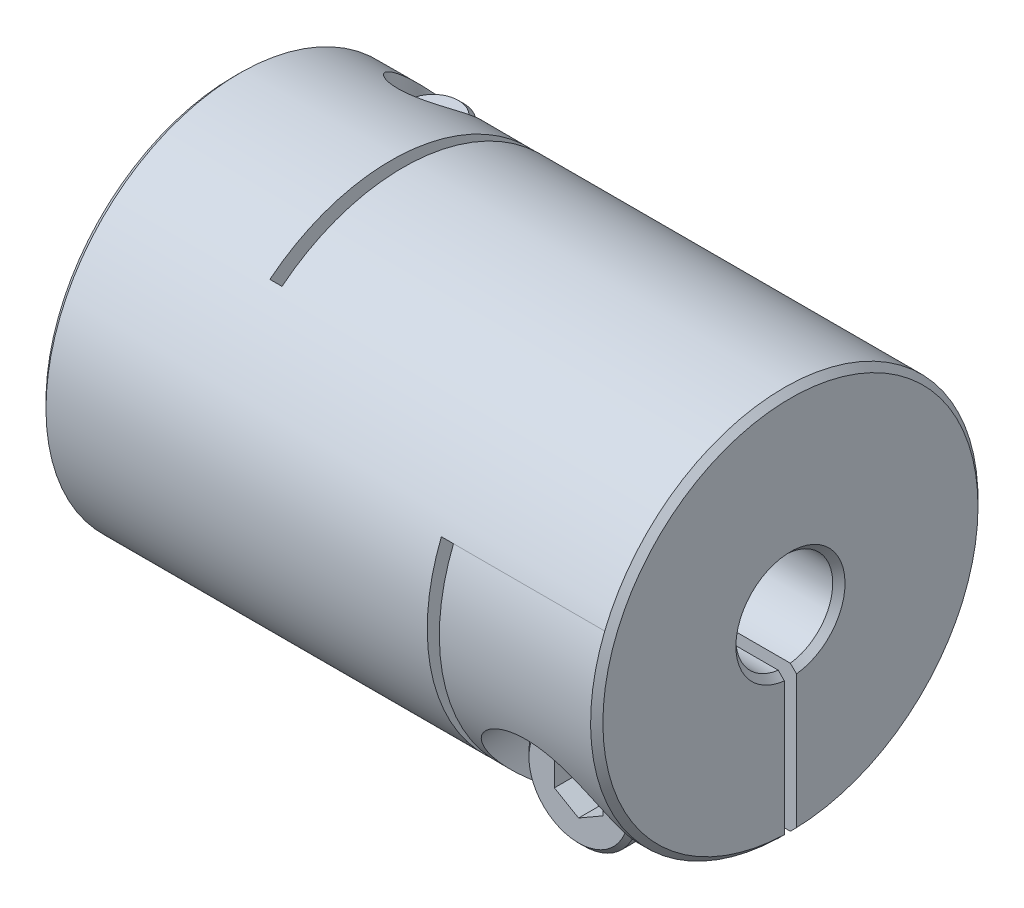
from build123d import *

# Parameters (mm, degrees)
SKETCH1_R                        = 8
BOSS_EXTRUDE1_DEPTH              = 11.5
SKETCH2_R                        = 2
CUT_EXTRUDE1_DEPTH               = 24
CHAMFER1_SIZE                    = 0.254
SKETCH4_W                        = 0.5
SKETCH4_H                        = 13
CUT_EXTRUDE2_DEPTH               = 17
SKETCH7_W                        = 0.5
SKETCH7_H                        = 11
CUT_EXTRUDE3_DEPTH               = 17
SKETCH8_W                        = 6.5
SKETCH8_H                        = 8
CUT_EXTRUDE5_DEPTH               = 0.25
SKETCH13_W                       = 6.5
SKETCH13_H                       = 8
CUT_EXTRUDE6_DEPTH               = 0.25
CBORE_FOR_M2_5_SHCS1_D           = 2.9
CBORE_FOR_M2_5_SHCS1_CBORE_D     = 5.5
CBORE_FOR_M2_5_SHCS1_CBORE_DEPTH = 5
CBORE_FOR_M2_5_SHCS2_D           = 2.9
CBORE_FOR_M2_5_SHCS2_CBORE_D     = 5.5
CBORE_FOR_M2_5_SHCS2_CBORE_DEPTH = 5
SKETCH16_R                       = 2.25
BOSS_EXTRUDE2_DEPTH              = 2.5
SKETCH17_R                       = 1.25
BOSS_EXTRUDE3_DEPTH              = 8.5
CHAMFER2_SIZE                    = 0.2
CUT_EXTRUDE7_DEPTH               = 1.5
CIRPATTERN1_COUNT                = 2
CIRPATTERN1_ANGLE                = 90


with BuildPart() as part:
    # Sketch1 → Boss-Extrude1 (new body, symmetric)
    with BuildSketch(Plane(origin=(0, 0, 0), x_dir=(0, 0, -1), z_dir=(1, 0, 0))):
        Circle(SKETCH1_R)
    extrude(amount=BOSS_EXTRUDE1_DEPTH, both=True)

    # Sketch2 → Cut-Extrude1 (cut, through all)
    with BuildSketch(Plane(origin=(11.5, 0, 0), x_dir=(0, 0, -1), z_dir=(1, 0, 0))):
        Circle(SKETCH2_R)
    extrude(amount=-CUT_EXTRUDE1_DEPTH, mode=Mode.SUBTRACT)

    # Chamfer1
    chamfer1_edges = [part.edges().sort_by_distance(p)[0] for p in [
        (-11.5, 0, 8),
        (11.5, 0, 8),
        (-11.5, 0, 2),
        (11.5, 0, 2),
    ]]
    chamfer(chamfer1_edges, length=CHAMFER1_SIZE)

    # Sketch4 → Cut-Extrude2 (cut, through all)
    with BuildSketch(Plane.XZ.offset(8)):
        with Locations((-4.75, -1.5)):
            Rectangle(SKETCH4_W, SKETCH4_H)
    extrude(amount=-CUT_EXTRUDE2_DEPTH, mode=Mode.SUBTRACT)

    # Sketch7 → Cut-Extrude3 (cut, through all)
    with BuildSketch(Plane(origin=(0, 0, -8), x_dir=(-1, 0, 0), z_dir=(0, 0, -1))):
        with Locations((-4.75, -2.5)):
            Rectangle(SKETCH7_W, SKETCH7_H)
    extrude(amount=-CUT_EXTRUDE3_DEPTH, mode=Mode.SUBTRACT)

    # Sketch8 → Cut-Extrude5 (cut, symmetric)
    with BuildSketch(Plane(origin=(0, 0, 0), x_dir=(1, 0, 0), z_dir=(0, 1, 0))):
        with Locations((-8.25, 4)):
            Rectangle(SKETCH8_W, SKETCH8_H)
    extrude(amount=CUT_EXTRUDE5_DEPTH, both=True, mode=Mode.SUBTRACT)

    # Sketch13 → Cut-Extrude6 (cut, symmetric)
    with BuildSketch(Plane.XY):
        with Locations((8.25, -4)):
            Rectangle(SKETCH13_W, SKETCH13_H)
    extrude(amount=CUT_EXTRUDE6_DEPTH, both=True, mode=Mode.SUBTRACT)

    # CBORE for M2.5 SHCS1 (through all)
    with Locations(Plane.XZ.offset(8)):
        with Locations((-8.25, -4.99020314)):
            CounterBoreHole(CBORE_FOR_M2_5_SHCS1_D / 2, CBORE_FOR_M2_5_SHCS1_CBORE_D / 2, CBORE_FOR_M2_5_SHCS1_CBORE_DEPTH)

    # CBORE for M2.5 SHCS2 (through all)
    with Locations(Plane.XY.offset(8)):
        with Locations((8.25, -4.99020314)):
            CounterBoreHole(CBORE_FOR_M2_5_SHCS2_D / 2, CBORE_FOR_M2_5_SHCS2_CBORE_D / 2, CBORE_FOR_M2_5_SHCS2_CBORE_DEPTH)


with BuildPart() as body_2:
    # Sketch16 → Boss-Extrude2 (new body)
    with BuildSketch(Plane.XY.offset(3)):
        with Locations((8.25, -4.99020314)):
            Circle(SKETCH16_R)
    extrude(amount=BOSS_EXTRUDE2_DEPTH)

    # Sketch17 → Boss-Extrude3 (add)
    with BuildSketch(Plane(origin=(0, 0, 3), x_dir=(-1, 0, 0), z_dir=(0, 0, -1))):
        with Locations(Location((-8.25, -4.99020314, 0), (0, 0, 180))):  # turned: the seam where the file's is
            Circle(SKETCH17_R)
    extrude(amount=BOSS_EXTRUDE3_DEPTH)

    # Chamfer2
    chamfer2_edges = [body_2.edges().sort_by_distance(p)[0] for p in [
        (6, -4.99020314, 3),
        (6, -4.99020314, 5.5),
        (7, -4.99020314, -5.5),
    ]]
    chamfer(chamfer2_edges, length=CHAMFER2_SIZE)

    # Sketch18 → Cut-Extrude7 (cut)
    with BuildSketch(Plane.XY.offset(5.5)):
        Polygon((8.25, -6.144903678), (9.25, -5.567553409), (9.25, -4.41285287), (8.25, -3.835502601), (7.25, -4.41285287), (7.25, -5.567553409), align=None)
    extrude(amount=-CUT_EXTRUDE7_DEPTH, mode=Mode.SUBTRACT)


with BuildPart() as body_3:
    # Mirror1: mirrored copy
    add(body_2.part.mirror(Plane(origin=(0, 0, 0), x_dir=(0, 0, 1), z_dir=(1, 0, 0))))


with BuildPart() as cirpattern1_1:
    # CirPattern1: pattern copy
    add(body_3.part.rotate(Axis((0, 0, 0), (1, 0, 0)), 1 * CIRPATTERN1_ANGLE / (CIRPATTERN1_COUNT - 1)))


solid = Compound([part.part, body_2.part, cirpattern1_1.part])
